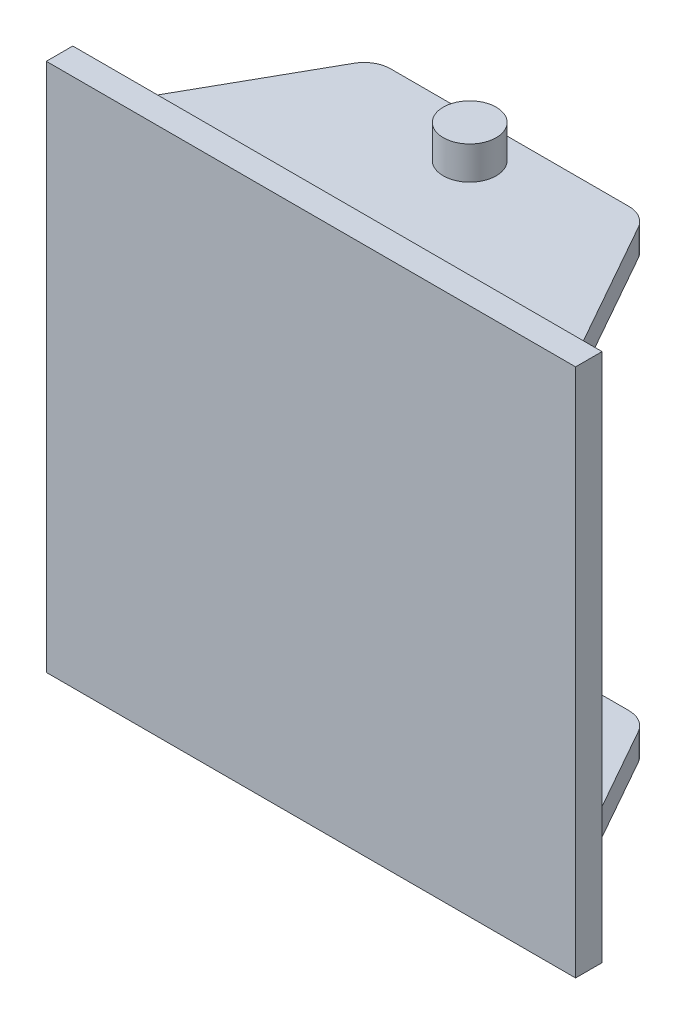
from build123d import *

# Parameters (mm, degrees)
SKETCH1_W           = 200
SKETCH1_H           = 200
BOSS_EXTRUDE1_DEPTH = 10
SKETCH2_W           = 175
SKETCH2_H           = 175
BOSS_EXTRUDE2_DEPTH = 75
CUT_EXTRUDE2_DEPTH  = 188.5
SKETCH6_W           = 50.093360238
SKETCH6_H           = 155
CUT_EXTRUDE3_DEPTH  = 100
SKETCH7_R           = 10
BOSS_EXTRUDE4_DEPTH = 100


with BuildPart() as part:
    # Sketch1 → Boss-Extrude1 (new body)
    with BuildSketch(Plane.XY):
        Rectangle(SKETCH1_W, SKETCH1_H)
    extrude(amount=BOSS_EXTRUDE1_DEPTH)

    # Sketch2 → Boss-Extrude2 (add)
    with BuildSketch(Plane(origin=(0, 0, 0), x_dir=(-1, 0, 0), z_dir=(0, 0, -1))):
        Rectangle(SKETCH2_W, SKETCH2_H)
    extrude(amount=BOSS_EXTRUDE2_DEPTH)

    # Sketch5 → Cut-Extrude2 (cut, through all)
    with BuildSketch(Plane(origin=(0, 87.5, 0), x_dir=(1, 0, 0), z_dir=(0, 1, 0))):
        with BuildLine():
            Line((-87.5, 0), (-53.713488753, 60))
            ThreePointArc((-53.713488753, 60), (-50.046464226, 63.72662143), (-45, 65.093360238))
            Line((-45, 65.093360238), (45, 65.093360238))
            ThreePointArc((45, 65.093360238), (50.046464226, 63.72662143), (53.713488753, 60))
            Line((53.713488753, 60), (87.5, 0))
            Line((87.5, 0), (87.5, 75))
            Line((87.5, 75), (-87.5, 75))
            Line((-87.5, 75), (-87.5, 0))
        make_face()
    extrude(amount=-CUT_EXTRUDE2_DEPTH, mode=Mode.SUBTRACT)

    # Sketch6 → Cut-Extrude3 (cut, symmetric)
    with BuildSketch(Plane(origin=(0, 0, 0), x_dir=(0, 0, -1), z_dir=(1, 0, 0))):
        with Locations((40.046680119, 0)):
            Rectangle(SKETCH6_W, SKETCH6_H)
    extrude(amount=CUT_EXTRUDE3_DEPTH, both=True, mode=Mode.SUBTRACT)

    # Sketch7 → Boss-Extrude4 (add, symmetric)
    with BuildSketch(Plane(origin=(0, 0, 0), x_dir=(1, 0, 0), z_dir=(0, 1, 0))):
        with Locations((0, 50)):
            Circle(SKETCH7_R)
    extrude(amount=BOSS_EXTRUDE4_DEPTH, both=True)


solid = part.part
